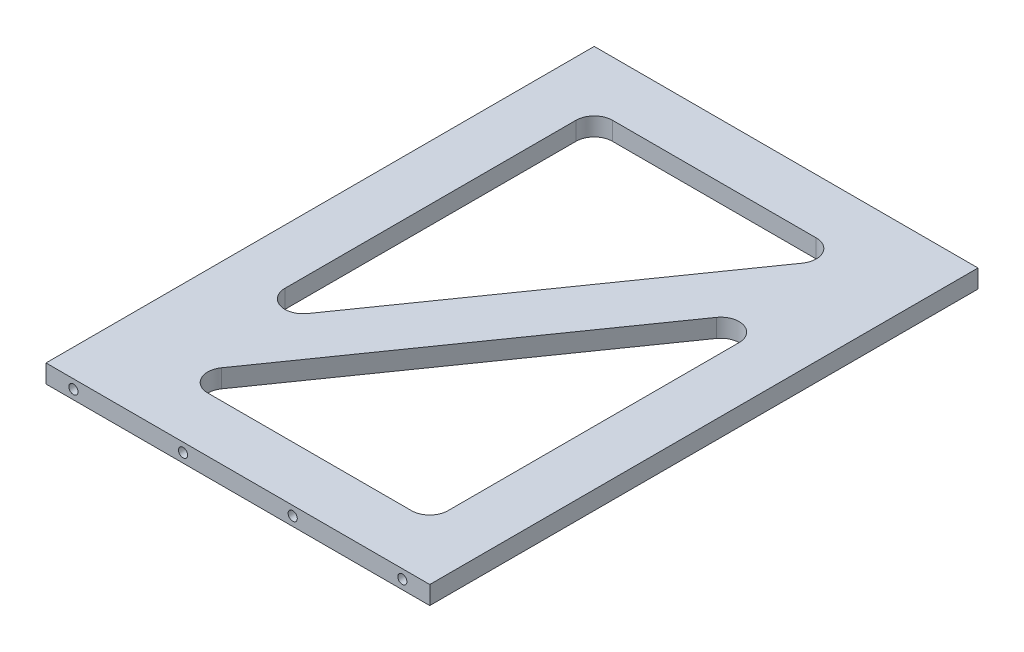
from build123d import *

# Parameters (mm, degrees)
SKETCH1_W             = 210
SKETCH1_H             = 300
BOSS_EXTRUDE1_DEPTH   = 10
CUT_EXTRUDE1_DEPTH    = 11
CUT_EXTRUDE2_DEPTH    = 11
FILLET1_R             = 10
M6_TAPPED_HOLE2_D     = 5
M6_TAPPED_HOLE2_DEPTH = 23
M6_TAPPED_HOLE2_TIP   = 1.502151548
M6_TAPPED_HOLE3_D     = 5
M6_TAPPED_HOLE3_DEPTH = 20
M6_TAPPED_HOLE3_TIP   = 1.502151548


with BuildPart() as part:
    # Sketch1 → Boss-Extrude1 (new body)
    with BuildSketch(Plane(origin=(0, 0, 0), x_dir=(1, 0, 0), z_dir=(0, 1, 0))):
        with Locations((105, 150)):
            Rectangle(SKETCH1_W, SKETCH1_H)
    extrude(amount=BOSS_EXTRUDE1_DEPTH)

    # Sketch2 → Cut-Extrude1 (cut, through all)
    with BuildSketch(Plane(origin=(0, 10, 0), x_dir=(1, 0, 0), z_dir=(0, 1, 0))):
        Polygon((39.309833424, 30), (180, 30), (180, 230.985952252), align=None)
    extrude(amount=-CUT_EXTRUDE1_DEPTH, mode=Mode.SUBTRACT)

    # Sketch3 → Cut-Extrude2 (cut, through all)
    with BuildSketch(Plane(origin=(0, 10, 0), x_dir=(1, 0, 0), z_dir=(0, 1, 0))):
        Polygon((30, 69.014047748), (30, 270), (170.690166576, 270), align=None)
    extrude(amount=-CUT_EXTRUDE2_DEPTH, mode=Mode.SUBTRACT)

    # Fillet1
    fillet1_edges = [part.edges().sort_by_distance(p)[0] for p in [
        (39.309833424, 5, -30),
        (180, 5, -230.985952252),
        (180, 5, -30),
        (170.690166576, 5, -270),
        (30, 5, -69.014047748),
        (30, 5, -270),
    ]]
    fillet(fillet1_edges, radius=FILLET1_R)

    # M6 Tapped Hole2
    with Locations(Plane.XY):
        with Locations((15, 5), (135, 5), (195, 5), (75, 5)):
            Hole(M6_TAPPED_HOLE2_D / 2, depth=M6_TAPPED_HOLE2_DEPTH)
            with Locations((0, 0, -(M6_TAPPED_HOLE2_DEPTH + M6_TAPPED_HOLE2_TIP / 2))):  # 118° drill point
                Cone(0, M6_TAPPED_HOLE2_D / 2, M6_TAPPED_HOLE2_TIP, mode=Mode.SUBTRACT)

    # M6 Tapped Hole3
    with Locations(Plane(origin=(0, 0, -300), x_dir=(-1, 0, 0), z_dir=(0, 0, -1))):
        with Locations((-195, 5), (-15, 5), (-135, 5), (-75, 5)):
            Hole(M6_TAPPED_HOLE3_D / 2, depth=M6_TAPPED_HOLE3_DEPTH)
            with Locations((0, 0, -(M6_TAPPED_HOLE3_DEPTH + M6_TAPPED_HOLE3_TIP / 2))):  # 118° drill point
                Cone(0, M6_TAPPED_HOLE3_D / 2, M6_TAPPED_HOLE3_TIP, mode=Mode.SUBTRACT)


solid = part.part
